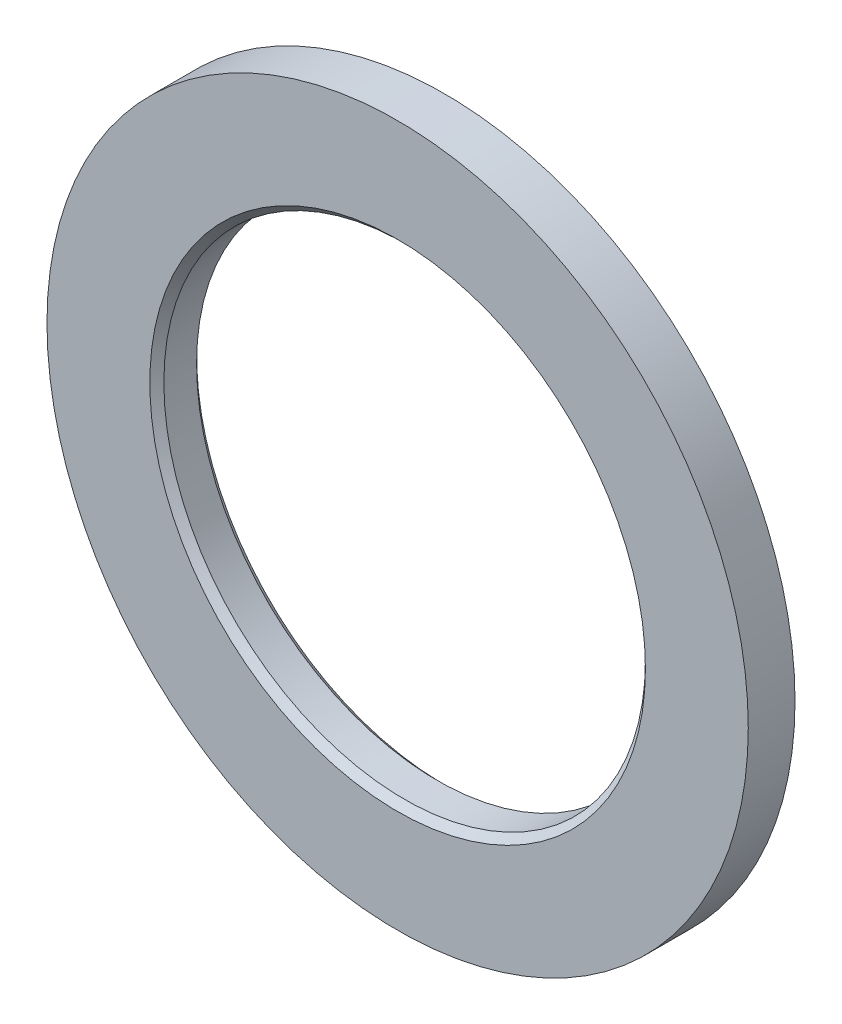
from build123d import *

# Parameters (mm, degrees)
GUARD_BASE_R     = 37.5
GUARD_DEPTH      = 5
AXLE_HOLE_BASE_R = 25.75
AXLE_HOLE_DEPTH  = 6


with BuildPart() as part:
    # Guard base → Guard (new body)
    with BuildSketch(Plane.XY):
        Circle(GUARD_BASE_R)
    extrude(amount=GUARD_DEPTH)

    # Axle hole base → Axle hole (cut, through all)
    with BuildSketch(Plane.XY.offset(5)):
        Circle(AXLE_HOLE_BASE_R)
    extrude(amount=-AXLE_HOLE_DEPTH, mode=Mode.SUBTRACT)

    # Mate ring room base → Mate ring room (revolve, cut)
    with BuildSketch(Plane(origin=(0, 0, 0), x_dir=(1, 0, 0), z_dir=(0, 1, 0))):
        Polygon((25.75, -5), (26.5, -5), (25.75, -4.25), align=None)
        Polygon((25.75, 0), (26.5, 0), (25.75, -0.75), align=None)
    revolve(axis=Axis((0, 0, 0), (0, 0, -1)), mode=Mode.SUBTRACT)


solid = part.part
